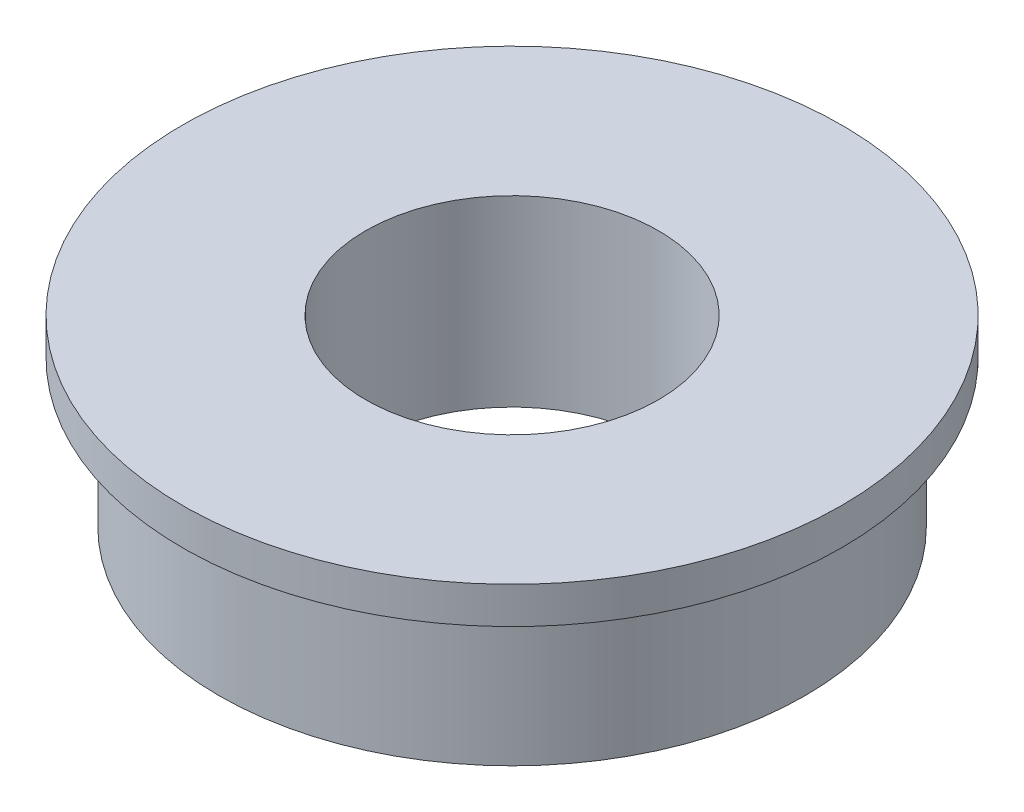
from build123d import *


with BuildPart() as part:
    # Sketch1 → Revolve1 (revolve)
    with BuildSketch(Plane.XY):
        Polygon((8, -0.69876818), (4, -0.69876818), (4, 4.30123182), (8, 4.30123182), (9, 4.30123182), (9, 3.30123182), (8, 3.30123182), align=None)
    revolve(axis=Axis((0, -8.487488151, 0), (0, 1, 0)))


solid = part.part
